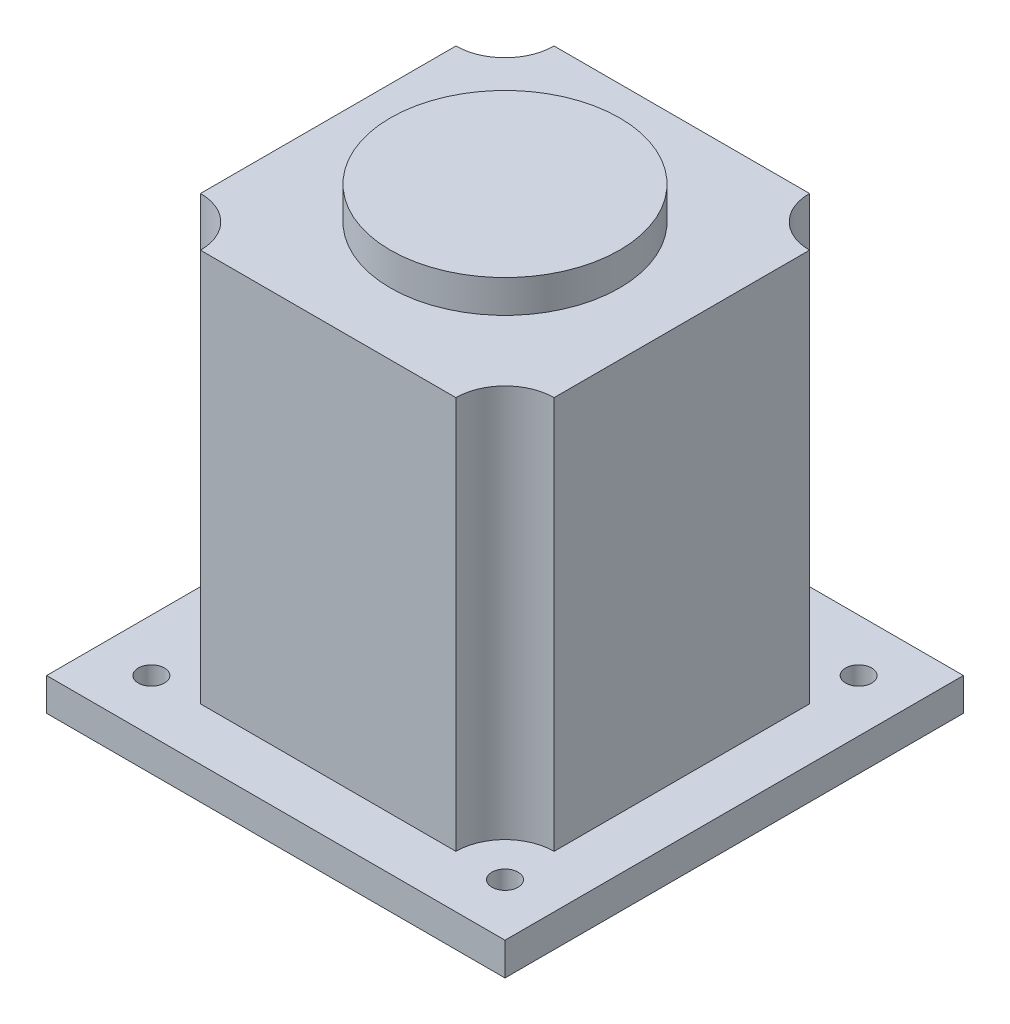
from build123d import *

# Parameters (mm, degrees)
SKETCH_1_W      = 140
SKETCH_1_H      = 140
SKETCH_1_R      = 4
EXTRUDE_1_DEPTH = 10
EXTRUDE_2_DEPTH = 120
SKETCH_3_R      = 35
EXTRUDE_3_DEPTH = 10
SKETCH_4_R      = 8
EXTRUDE_4_DEPTH = 5


with BuildPart() as part:
    # 草图1 → 凸台-拉伸1 (new body)
    with BuildSketch(Plane(origin=(0, 0, 0), x_dir=(1, 0, 0), z_dir=(0, 1, 0))):
        Rectangle(SKETCH_1_W, SKETCH_1_H)
        with Locations((54, 54)):
            Circle(SKETCH_1_R, mode=Mode.SUBTRACT)
        with Locations((54, -54)):
            Circle(SKETCH_1_R, mode=Mode.SUBTRACT)
        with Locations((-54, -54)):
            Circle(SKETCH_1_R, mode=Mode.SUBTRACT)
        with Locations((-54, 54)):
            Circle(SKETCH_1_R, mode=Mode.SUBTRACT)
    extrude(amount=EXTRUDE_1_DEPTH)

    # 草图2 → 凸台-拉伸2 (add)
    with BuildSketch(Plane(origin=(0, 10, 0), x_dir=(1, 0, 0), z_dir=(0, 1, 0))):
        with BuildLine():
            Line((39, 54), (-39, 54))
            ThreePointArc((-39, 54), (-43.393398282, 43.393398282), (-54, 39))
            Line((-54, 39), (-54, -39))
            ThreePointArc((-54, -39), (-43.393398282, -43.393398282), (-39, -54))
            Line((-39, -54), (39, -54))
            ThreePointArc((39, -54), (43.393398282, -43.393398282), (54, -39))
            Line((54, -39), (54, 39))
            ThreePointArc((54, 39), (43.393398282, 43.393398282), (39, 54))
        make_face()
    extrude(amount=EXTRUDE_2_DEPTH)

    # 草图3 → 凸台-拉伸3 (add)
    with BuildSketch(Plane(origin=(0, 130, 0), x_dir=(1, 0, 0), z_dir=(0, 1, 0))):
        Circle(SKETCH_3_R)
    extrude(amount=EXTRUDE_3_DEPTH)

    # 草图4 → 凸台-拉伸4 (add)
    with BuildSketch(Plane.XZ):
        Circle(SKETCH_4_R)
    extrude(amount=EXTRUDE_4_DEPTH)


solid = part.part
